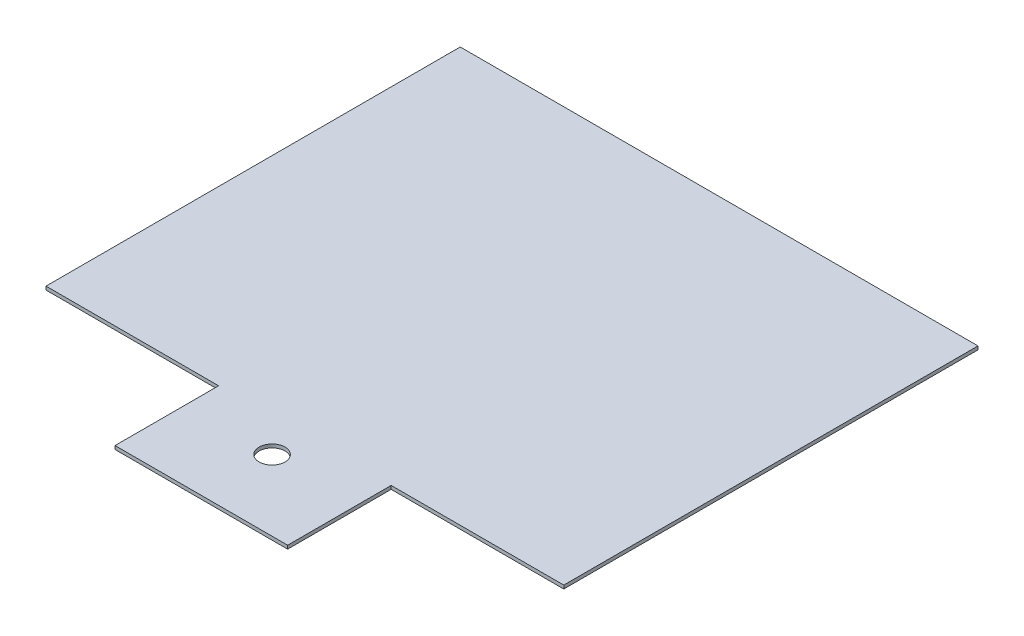
from build123d import *

# Parameters (mm, degrees)
BOSS_EXTRUDE1_DEPTH = 2
SKETCH2_R           = 7.5
CUT_EXTRUDE1_DEPTH  = 10


with BuildPart() as part:
    # Sketch1 → Boss-Extrude1 (new body)
    with BuildSketch(Plane(origin=(0, 0, 0), x_dir=(1, 0, 0), z_dir=(0, 1, 0))):
        Polygon((-50, 250), (-150, 250), (-150, 10), (-50, 10), (-50, -50), (50, -50), (50, 10), (150, 10), (150, 250), (50, 250), align=None)
    extrude(amount=BOSS_EXTRUDE1_DEPTH)

    # Sketch2 → Cut-Extrude1 (cut)
    with BuildSketch(Plane(origin=(0, 0, 0), x_dir=(-1, 0, 0), z_dir=(0, -1, 0))):
        with Locations((0, -9)):
            Circle(SKETCH2_R)
    extrude(amount=-CUT_EXTRUDE1_DEPTH, mode=Mode.SUBTRACT)


solid = part.part
